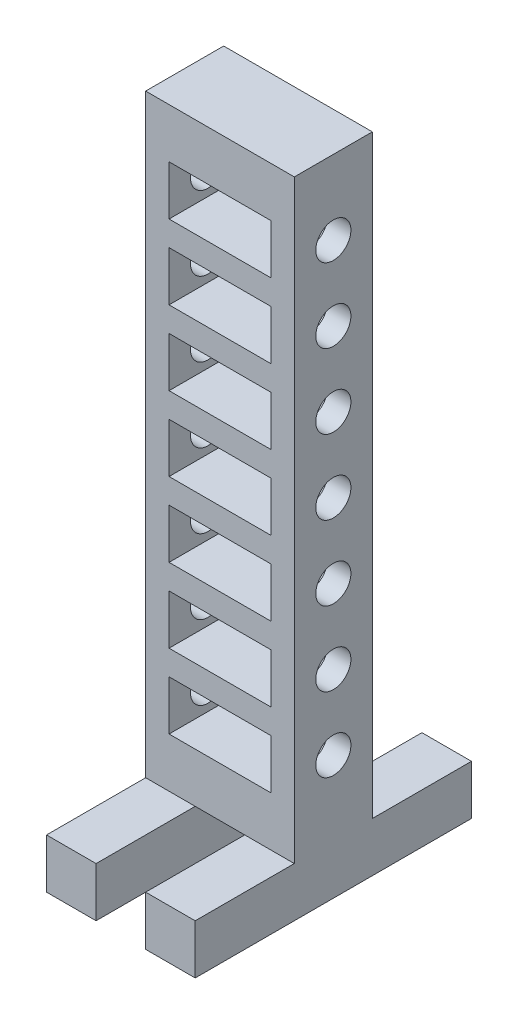
from build123d import *

# Parameters (mm, degrees)
SKETCH1_W           = 19.05
SKETCH1_H           = 76.2
SKETCH1_W_2         = 13.05
SKETCH1_H_2         = 6.35
BOSS_EXTRUDE1_DEPTH = 10
SKETCH2_W           = 6.35
SKETCH2_H           = 35.4
BOSS_EXTRUDE2_DEPTH = 6.35
SKETCH3_R           = 2.25
CUT_EXTRUDE1_DEPTH  = 30


with BuildPart() as part:
    # Sketch1 → Boss-Extrude1 (new body)
    with BuildSketch(Plane.XY):
        with Locations((9.525, 38.1)):
            Rectangle(SKETCH1_W, SKETCH1_H)
        with Locations((9.525, 66.675)):
            Rectangle(SKETCH1_W_2, SKETCH1_H_2, mode=Mode.SUBTRACT)
        with Locations((9.525, 57.15)):
            Rectangle(SKETCH1_W_2, SKETCH1_H_2, mode=Mode.SUBTRACT)
        with Locations((9.525, 47.625)):
            Rectangle(SKETCH1_W_2, SKETCH1_H_2, mode=Mode.SUBTRACT)
        with Locations((9.525, 38.1)):
            Rectangle(SKETCH1_W_2, SKETCH1_H_2, mode=Mode.SUBTRACT)
        with Locations((9.525, 28.575)):
            Rectangle(SKETCH1_W_2, SKETCH1_H_2, mode=Mode.SUBTRACT)
        with Locations((9.525, 19.05)):
            Rectangle(SKETCH1_W_2, SKETCH1_H_2, mode=Mode.SUBTRACT)
        with Locations((9.525, 9.525)):
            Rectangle(SKETCH1_W_2, SKETCH1_H_2, mode=Mode.SUBTRACT)
    extrude(amount=BOSS_EXTRUDE1_DEPTH)

    # Sketch2 → Boss-Extrude2 (add)
    with BuildSketch(Plane.XZ):
        with Locations((3.175, 5)):
            Rectangle(SKETCH2_W, SKETCH2_H)
        with Locations((15.875, 5)):
            Rectangle(SKETCH2_W, SKETCH2_H)
    extrude(amount=BOSS_EXTRUDE2_DEPTH)

    # Sketch3 → Cut-Extrude1 (cut)
    with BuildSketch(Plane(origin=(19.05, 0, 0), x_dir=(0, 0, -1), z_dir=(1, 0, 0))):
        with Locations((-5, 66.675)):
            Circle(SKETCH3_R)
        with Locations((-5, 57.15)):
            Circle(SKETCH3_R)
        with Locations((-5, 47.625)):
            Circle(SKETCH3_R)
        with Locations((-5, 38.1)):
            Circle(SKETCH3_R)
        with Locations((-5, 28.575)):
            Circle(SKETCH3_R)
        with Locations((-5, 19.05)):
            Circle(SKETCH3_R)
        with Locations((-5, 9.525)):
            Circle(SKETCH3_R)
    extrude(amount=-CUT_EXTRUDE1_DEPTH, mode=Mode.SUBTRACT)


solid = part.part
